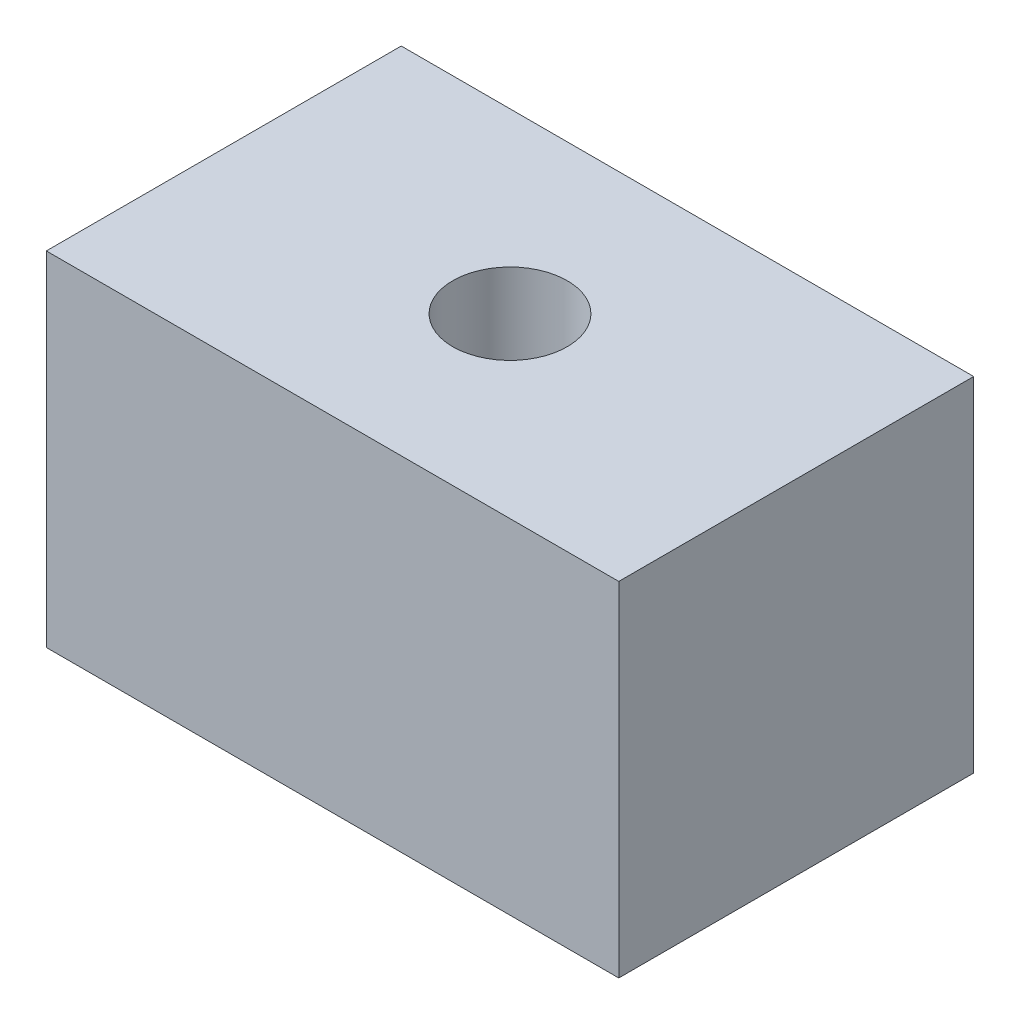
from build123d import *

# Parameters (mm, degrees)
SKETCH1_W           = 25
SKETCH1_H           = 15.5
BOSS_EXTRUDE1_DEPTH = 15
SKETCH2_R           = 2.5
CUT_EXTRUDE1_DEPTH  = 10
SKETCH4_R           = 2.5
CUT_EXTRUDE3_DEPTH  = 4
SKETCH5_R           = 2.5
CUT_EXTRUDE4_DEPTH  = 4


with BuildPart() as part:
    # Sketch1 → Boss-Extrude1 (new body)
    with BuildSketch(Plane(origin=(0, 0, 0), x_dir=(1, 0, 0), z_dir=(0, 1, 0))):
        Rectangle(SKETCH1_W, SKETCH1_H)
    extrude(amount=BOSS_EXTRUDE1_DEPTH)

    # Sketch2 → Cut-Extrude1 (cut)
    with BuildSketch(Plane(origin=(0, 15, 0), x_dir=(1, 0, 0), z_dir=(0, 1, 0))):
        Circle(SKETCH2_R)
    extrude(amount=-CUT_EXTRUDE1_DEPTH, mode=Mode.SUBTRACT)

    # Sketch4 → Cut-Extrude3 (cut)
    with BuildSketch(Plane.XZ):
        with Locations((5, 0)):
            Circle(SKETCH4_R)
    extrude(amount=-CUT_EXTRUDE3_DEPTH, mode=Mode.SUBTRACT)

    # Sketch5 → Cut-Extrude4 (cut)
    with BuildSketch(Plane.XZ):
        with Locations((-5, 0)):
            Circle(SKETCH5_R)
    extrude(amount=-CUT_EXTRUDE4_DEPTH, mode=Mode.SUBTRACT)


solid = part.part
